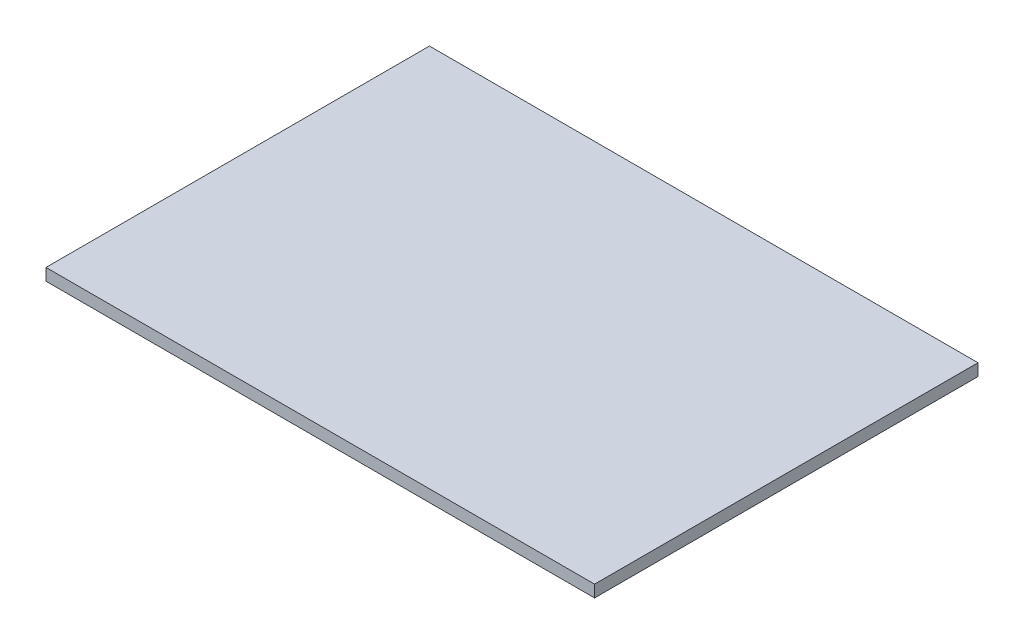
from build123d import *

# Parameters (mm, degrees)
SKETCH1_W           = 72.675
SKETCH1_H           = 50.8
BOSS_EXTRUDE1_DEPTH = 1.5875


with BuildPart() as part:
    # Sketch1 → Boss-Extrude1 (new body)
    with BuildSketch(Plane(origin=(0, 0, 0), x_dir=(1, 0, 0), z_dir=(0, 1, 0))):
        with Locations((3.514572667, -36.133009307)):
            Rectangle(SKETCH1_W, SKETCH1_H)
    extrude(amount=BOSS_EXTRUDE1_DEPTH)


solid = part.part
